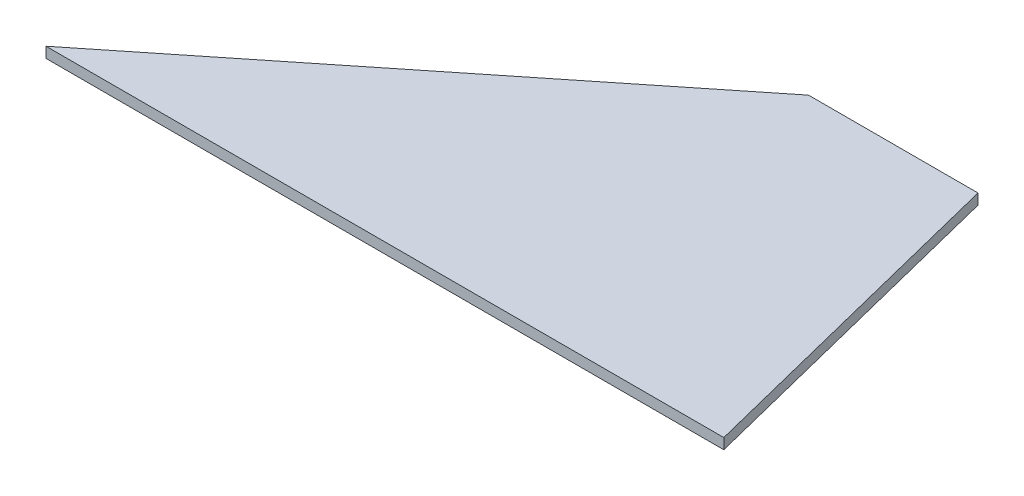
from build123d import *

# Parameters (mm, degrees)
BOSS_EXTRUDE1_DEPTH = 6.35


with BuildPart() as part:
    # Sketch1 → Boss-Extrude1 (new body)
    with BuildSketch(Plane(origin=(0, 0, 0), x_dir=(1, 0, 0), z_dir=(0, 1, 0))):
        Polygon((0, 0), (-406.4, 0), (-152.4, 203.2), (-50.8, 203.2), align=None)
    extrude(amount=BOSS_EXTRUDE1_DEPTH)


solid = part.part
